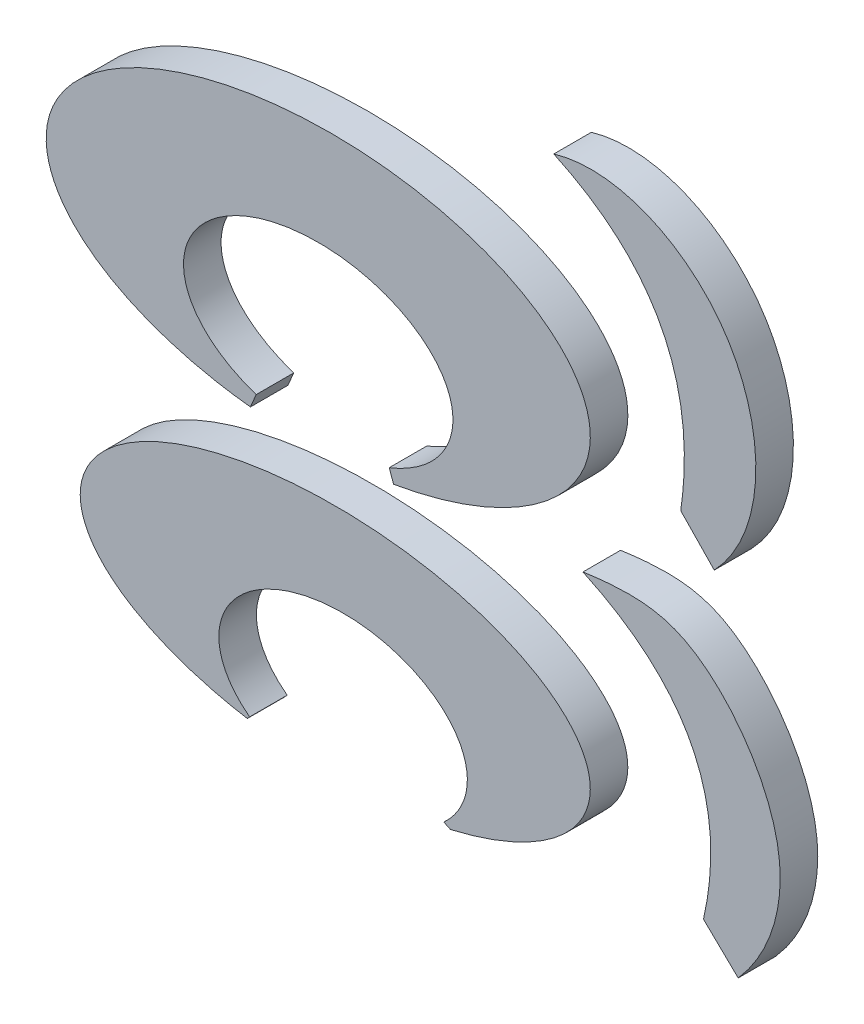
from build123d import *

# Parameters (mm, degrees)
BOSS_EXTRUDE2_DEPTH   = 1.27
BOSS_EXTRUDE2_2_DEPTH = 1.27
BOSS_EXTRUDE2_3_DEPTH = 1.27
BOSS_EXTRUDE2_4_DEPTH = 1.27


with BuildPart() as part:
    # Sketch3 → Boss-Extrude2 (new body)
    with BuildSketch(Plane.XY):
        with BuildLine():
            Line((-22.729472577, -0.331045559), (-22.923088104, -0.790331708))
            add(Edge.make_bspline(
                [(-18.08238395, -0.634868908), (-5.493223468, 1.54303818), (-13.176092636, 6.813740367), (-20.858961803, 12.084442553), (-28.23493195, 6.330114586), (-35.610902097, 0.57578662), (-22.923088104, -0.790331708)],
                knots=[4.975581932, 4.975581932, 4.975581932, 6.892522915, 6.892522915, 8.809463898, 8.809463898, 10.726404881, 10.726404881, 10.726404881], degree=2, weights=[1, 0.574772275, 1, 0.574772275, 1, 0.574772275, 1]))
            Line((-18.08238395, -0.634868908), (-18.227822056, -0.220866734))
            add(Edge.make_bspline(
                [(-18.227822056, -0.220866734), (-13.593645499, 1.621465315), (-17.247345891, 4.215826038), (-20.901046284, 6.810186762), (-24.235256407, 4.044795486), (-27.569466529, 1.279404211), (-22.729472577, -0.331045559)],
                knots=[5.267690951, 5.267690951, 5.267690951, 7.017336471, 7.017336471, 8.76698199, 8.76698199, 10.516627509, 10.516627509, 10.516627509], degree=2, weights=[1, 0.641132888, 1, 0.641132888, 1, 0.641132888, 1]))
        make_face()
    extrude(amount=BOSS_EXTRUDE2_DEPTH)


with BuildPart() as body_2:
    # Sketch3 → Boss-Extrude2 2 (new body)
    with BuildSketch(Plane.XY):
        with BuildLine():
            Line((-22.950491056, -9.882784835), (-23.029730546, -9.969846664))
            add(Edge.make_bspline(
                [(-16.159487512, -9.785062298), (-6.251001891, -7.470405648), (-13.561914518, -3.612215588), (-20.872827146, 0.245974473), (-27.163253279, -3.978041768), (-33.453679413, -8.20205801), (-23.029730546, -9.969846664)],
                knots=[5.180937198, 5.180937198, 5.180937198, 7.001773196, 7.001773196, 8.822609194, 8.822609194, 10.643445192, 10.643445192, 10.643445192], degree=2, weights=[1, 0.613415684, 1, 0.613415684, 1, 0.613415684, 1]))
            Line((-16.159487512, -9.785062298), (-16.381051815, -9.676766079))
            add(Edge.make_bspline(
                [(-16.381051815, -9.676766079), (-11.284051681, -4.990053078), (-19.987857918, -5.263005953), (-28.691664155, -5.535958828), (-22.950491056, -9.882784835)],
                knots=[5.658364192, 5.658364192, 5.658364192, 7.901235582, 7.901235582, 10.144106971, 10.144106971, 10.144106971], degree=2, weights=[1, 0.434389728, 1, 0.434389728, 1]))
        make_face()
    extrude(amount=BOSS_EXTRUDE2_2_DEPTH)


with BuildPart() as body_3:
    # Sketch3 → Boss-Extrude2 3 (new body)
    with BuildSketch(Plane.XY):
        with BuildLine():
            Line((-8.369479538, 3.448768662), (-7.235513319, 2.27430365))
            add(Edge.make_bspline(
                [(-12.662351651, 11.751021333), (-10.612907871, 12.358493414), (-5.519594424, 10.132577176), (-5.333940766, 4.268023794), (-7.235513319, 2.27430365)],
                knots=[0, 0, 0, 0, 0.441261893, 1, 1, 1, 1], degree=3))
            add(Edge.make_bspline(
                [(-12.662351651, 11.751021333), (-7.512431185, 9.355498399), (-8.369479538, 3.448768662)],
                knots=[0, 0, 0, 1, 1, 1], degree=2))
        make_face()
    extrude(amount=BOSS_EXTRUDE2_3_DEPTH)


with BuildPart() as body_4:
    # Sketch3 → Boss-Extrude2 4 (new body)
    with BuildSketch(Plane.XY):
        with BuildLine():
            Line((-7.600002461, -8.133886285), (-6.425537449, -9.267852504))
            add(Edge.make_bspline(
                [(-11.67601203, 0), (-9.837034151, 0.264112068), (-7.458116602, -0.030694782), (-4.196248125, -4.747539127), (-5.396290744, -8.105473275), (-6.425537449, -9.267852504)],
                knots=[0, 0, 0, 0, 0.278030672, 0.664567586, 1, 1, 1, 1], degree=3))
            add(Edge.make_bspline(
                [(-11.67601203, 0), (-6.320024575, -2.485327003), (-7.600002461, -8.133886285)],
                knots=[0, 0, 0, 1, 1, 1], degree=2))
        make_face()
    extrude(amount=BOSS_EXTRUDE2_4_DEPTH)


solid = Compound([part.part, body_2.part, body_3.part, body_4.part])
